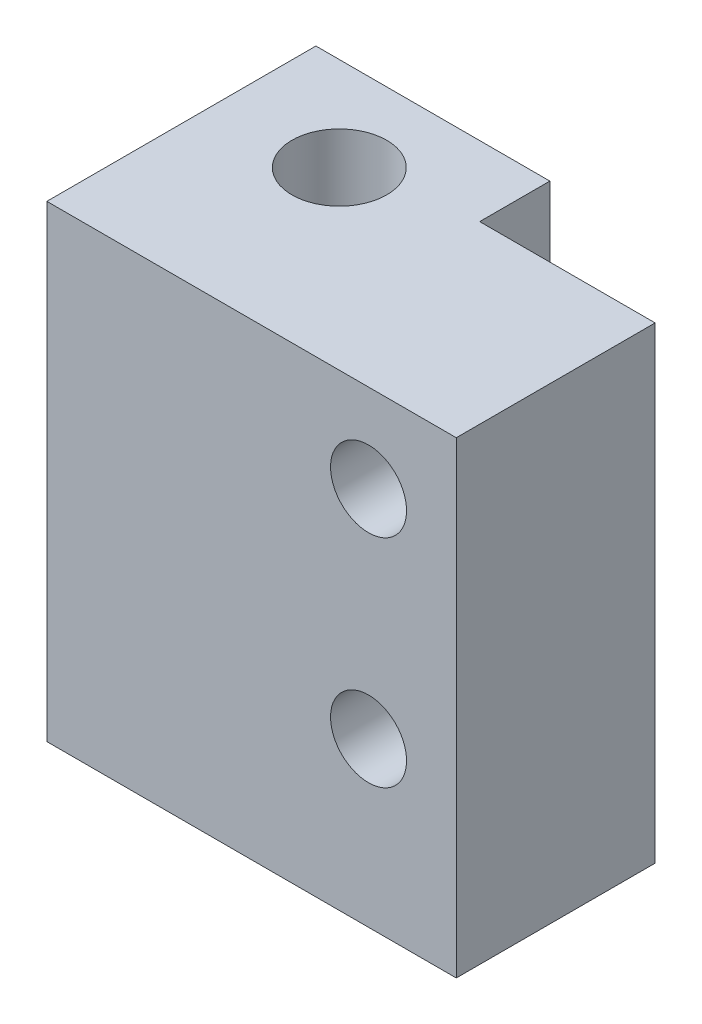
from build123d import *

# Parameters (mm, degrees)
BOSS_EXTRUDE2_DEPTH = 40
SKETCH3_R           = 4.05
CUT_EXTRUDE1_DEPTH  = 35
CUT_EXTRUDE2_REACH  = 19
SKETCH4_R           = 3.25
SKETCH6_R           = 1.5
CUT_EXTRUDE3_DEPTH  = 10


with BuildPart() as part:
    # Sketch1 → Boss-Extrude2 (new body)
    with BuildSketch(Plane(origin=(0, 0, 0), x_dir=(1, 0, 0), z_dir=(0, 1, 0))):
        Polygon((-10, -5.257459708), (-10, 0.742540292), (10, 0.742540292), (10, -5.257459708), (25, -5.257459708), (25, -22.257459708), (-10, -22.257459708), align=None)
    extrude(amount=BOSS_EXTRUDE2_DEPTH)

    # Sketch3 → Cut-Extrude1 (cut)
    with BuildSketch(Plane.XZ):
        with Locations((0, 7.257459708)):
            Circle(SKETCH3_R)
    extrude(amount=-CUT_EXTRUDE1_DEPTH, mode=Mode.SUBTRACT)

    # Sketch4 → Cut-Extrude2 (cut, up to next)
    with BuildSketch(Plane(origin=(0, 0, 5.257459708), x_dir=(-1, 0, 0), z_dir=(0, 0, -1)), mode=Mode.PRIVATE) as cut_extrude2_sk1:
        with Locations((-17.5, 26.045770547)):
            Circle(SKETCH4_R)
    cut_extrude2_tool1 = extrude(cut_extrude2_sk1.sketch, amount=-CUT_EXTRUDE2_REACH, mode=Mode.PRIVATE) & part.part
    add(cut_extrude2_tool1.solids().sort_by_distance((17.5, 26.045771, 5.25746))[0], mode=Mode.SUBTRACT)
    # Sketch4 → Cut-Extrude2 (cut, up to next)
    with BuildSketch(Plane(origin=(0, 0, 5.257459708), x_dir=(-1, 0, 0), z_dir=(0, 0, -1)), mode=Mode.PRIVATE) as cut_extrude2_sk2:
        with Locations((-17.5, 7.535290978)):
            Circle(SKETCH4_R)
    cut_extrude2_tool2 = extrude(cut_extrude2_sk2.sketch, amount=-CUT_EXTRUDE2_REACH, mode=Mode.PRIVATE) & part.part
    add(cut_extrude2_tool2.solids().sort_by_distance((17.5, 7.535291, 5.25746))[0], mode=Mode.SUBTRACT)

    # Sketch6 → Cut-Extrude3 (cut)
    with BuildSketch(Plane.XZ.offset(-35)):
        with Locations((0, 7.257459708)):
            Circle(SKETCH6_R)
    extrude(amount=-CUT_EXTRUDE3_DEPTH, mode=Mode.SUBTRACT)


with BuildPart() as body_2:
    # Mirror4: mirrored copy
    add(part.part.mirror(Plane.ZX))


solid = body_2.part
